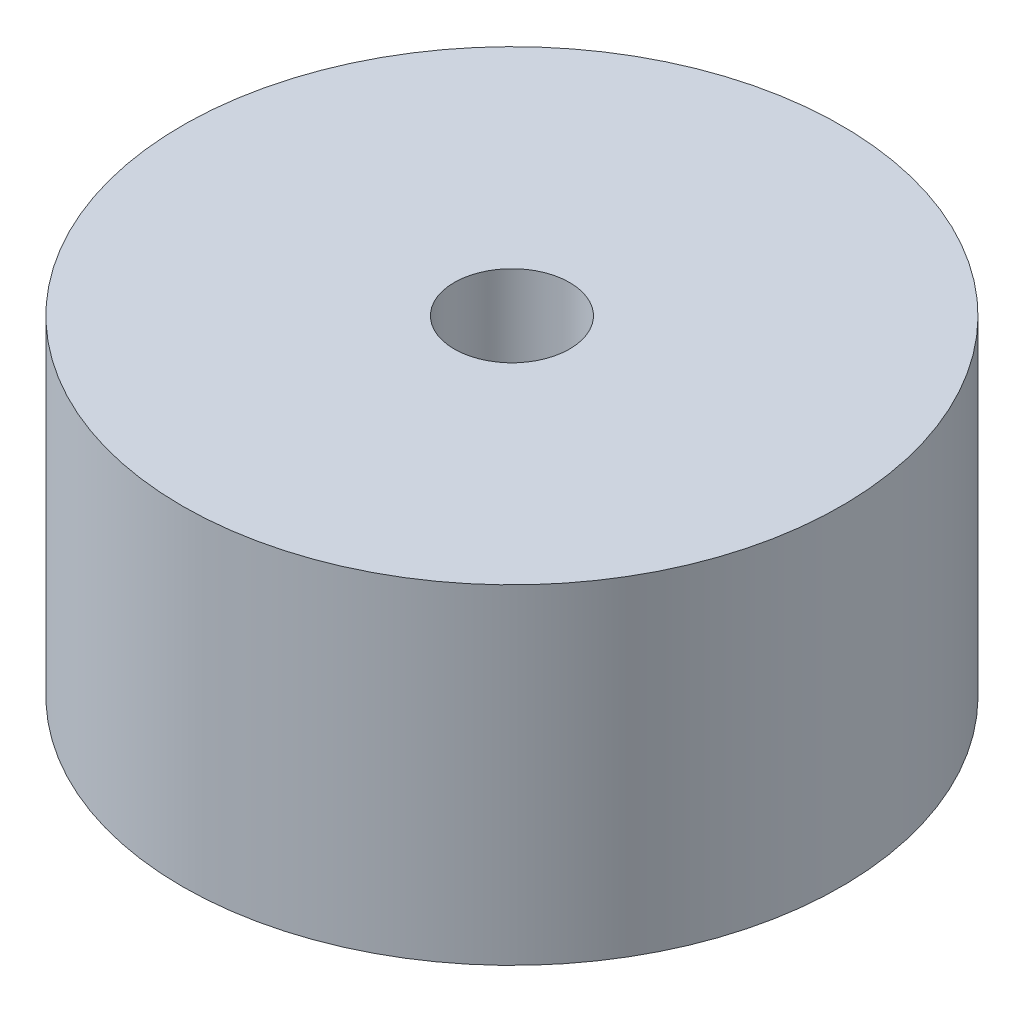
from build123d import *

# Parameters (mm, degrees)
SKETCH1_R           = 10
SKETCH1_R_2         = 1.75
BOSS_EXTRUDE1_DEPTH = 10
SKETCH2_R           = 3.2
CUT_EXTRUDE1_DEPTH  = 5


with BuildPart() as part:
    # Sketch1 → Boss-Extrude1 (new body)
    with BuildSketch(Plane(origin=(0, 0, 0), x_dir=(1, 0, 0), z_dir=(0, 1, 0))):
        Circle(SKETCH1_R)
        Circle(SKETCH1_R_2, mode=Mode.SUBTRACT)
    extrude(amount=BOSS_EXTRUDE1_DEPTH)

    # Sketch2 → Cut-Extrude1 (cut)
    with BuildSketch(Plane.XZ):
        Circle(SKETCH2_R)
    extrude(amount=-CUT_EXTRUDE1_DEPTH, mode=Mode.SUBTRACT)


solid = part.part
